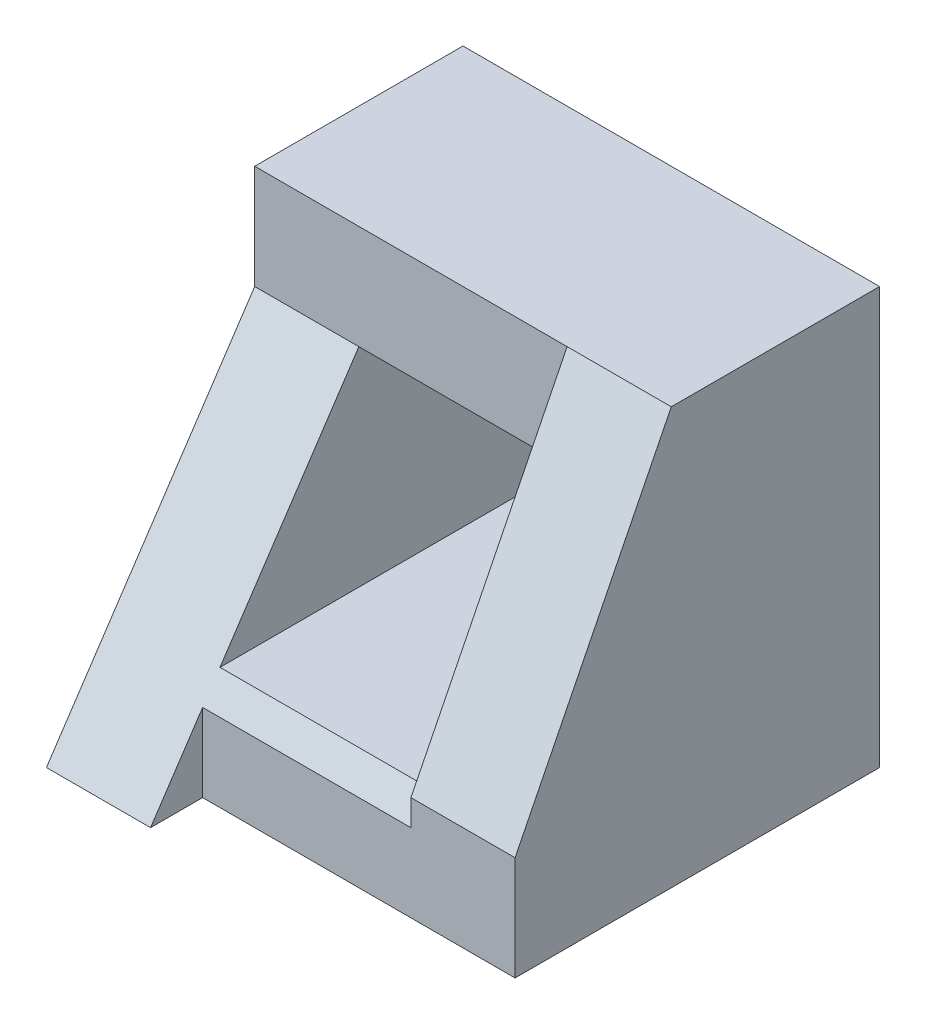
from build123d import *

# Parameters (mm, degrees)
SKETCH1_W           = 4
SKETCH1_H           = 4
SKETCH1_W_2         = 2
SKETCH1_H_2         = 2
BOSS_EXTRUDE1_DEPTH = 4
CUT_EXTRUDE1_DEPTH  = 4
CUT_EXTRUDE2_DEPTH  = 3
CUT_EXTRUDE3_DEPTH  = 3
CUT_EXTRUDE5_DEPTH  = 3


with BuildPart() as part:
    # Sketch1 → Boss-Extrude1 (new body)
    with BuildSketch(Plane.XY):
        with Locations((2, 2)):
            Rectangle(SKETCH1_W, SKETCH1_H)
        with Locations((2, 2)):
            Rectangle(SKETCH1_W_2, SKETCH1_H_2, mode=Mode.SUBTRACT)
    extrude(amount=BOSS_EXTRUDE1_DEPTH)

    # Sketch2 → Cut-Extrude1 (cut)
    with BuildSketch(Plane(origin=(4, 0, 0), x_dir=(0, 0, -1), z_dir=(1, 0, 0))):
        Polygon((-2, 4), (-4, 0), (-4, 4), align=None)
    extrude(amount=-CUT_EXTRUDE1_DEPTH, mode=Mode.SUBTRACT)

    # Sketch3 → Cut-Extrude2 (cut)
    with BuildSketch(Plane.ZY):
        Polygon((2, 4), (2, 3), (2.5, 3), align=None)
    extrude(amount=-CUT_EXTRUDE2_DEPTH, mode=Mode.SUBTRACT)

    # Sketch4 → Cut-Extrude3 (cut)
    with BuildSketch(Plane.ZY):
        Polygon((2, 3), (4, 0), (4, 3.222768016), align=None)
    extrude(amount=-CUT_EXTRUDE3_DEPTH, mode=Mode.SUBTRACT)

    # Sketch6 → Cut-Extrude5 (cut)
    with BuildSketch(Plane(origin=(4, 0, 0), x_dir=(0, 0, -1), z_dir=(1, 0, 0))):
        Polygon((-3.5, 0), (-3.5, 1), (-4, 0), align=None)
    extrude(amount=-CUT_EXTRUDE5_DEPTH, mode=Mode.SUBTRACT)


solid = part.part
